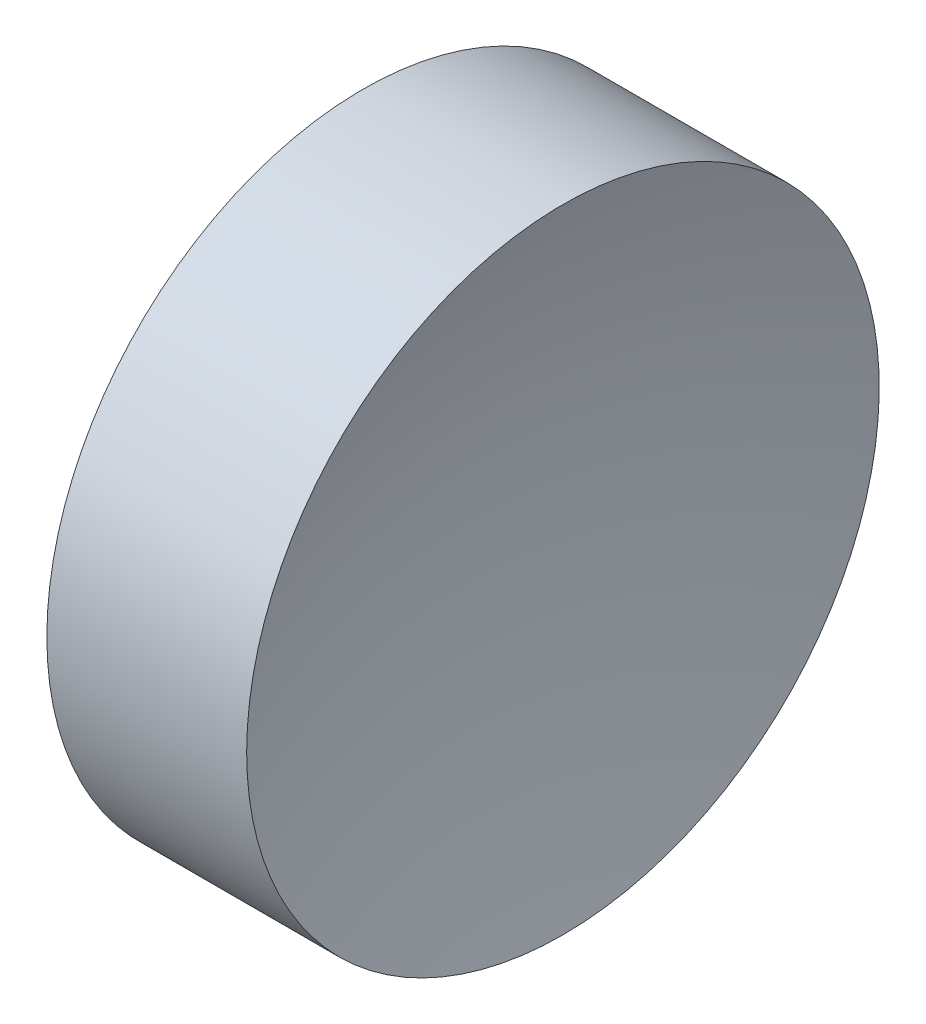
from build123d import *


with BuildPart() as part:
    # 草图1 → 旋转1 (revolve)
    with BuildSketch(Plane.XY, mode=Mode.PRIVATE) as revolve_1_sk:
        with BuildLine():
            Line((22.172189475, 13.044520575), (22.172189475, 16.194520575))
            Line((22.172189475, 16.194520575), (24.162189475, 16.194520575))
            ThreePointArc((24.162189475, 16.194520575), (23.795421692, 14.63846223), (23.672189475, 13.044520575))
            Line((23.672189475, 13.044520575), (22.172189475, 13.044520575))
        make_face()
    revolve(revolve_1_sk.sketch.rotate(Axis((21.224930557, 13.044520575, 0), (1, 0, 0)), 180), axis=Axis((21.224930557, 13.044520575, 0), (1, 0, 0)))  # turned: the seam where the file's is


solid = part.part
